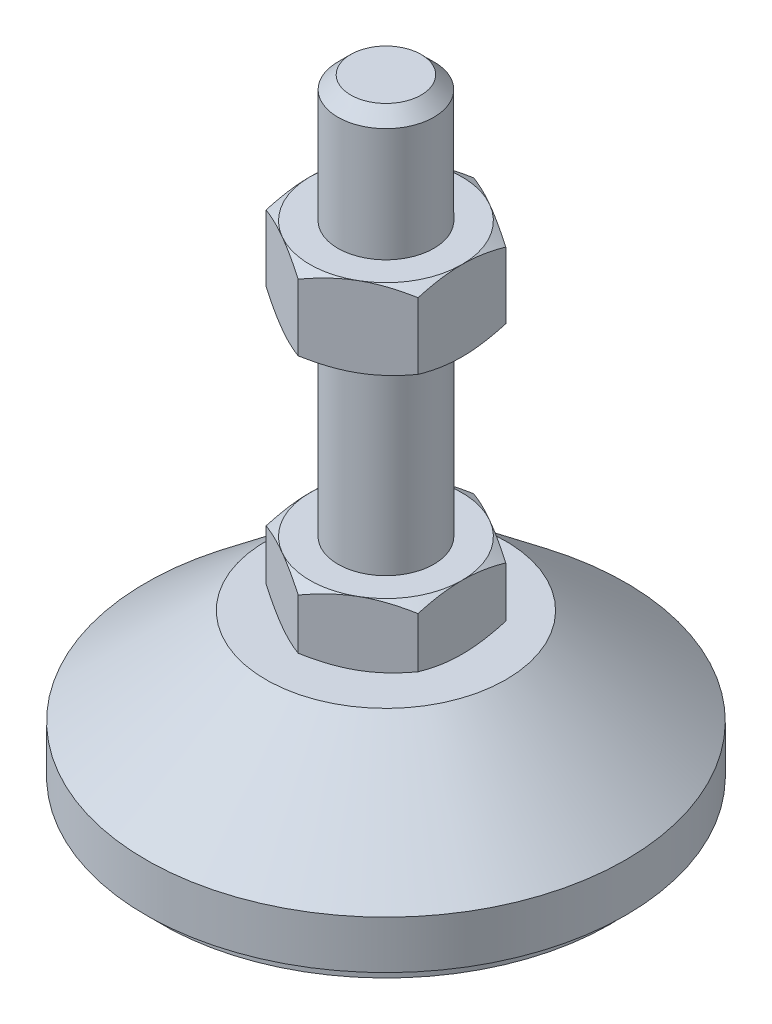
from build123d import *

# Parameters (mm, degrees)
EXTRUDE_1_DEPTH = 8
EXTRUDE_2_DEPTH = 10


with BuildPart() as part:
    # Эскиз1 → Повернуть1 (revolve)
    with BuildSketch(Plane.XY, mode=Mode.PRIVATE) as revolve_1_sk:
        Polygon((0, 0), (-28, 0), (-28, 2), (-30, 2), (-30, 8), (-15, 20), (-6, 20), (-6, 28), (-6, 76.4), (-4.4, 78), (0, 78), align=None)
    revolve(revolve_1_sk.sketch.rotate(Axis((0, 0, 0), (0, 1, 0)), 180), axis=Axis((0, 0, 0), (0, 1, 0)))  # turned: the seam where the file's is

    # Эскиз2 → Бобышка-Вытянуть1 (add)
    with BuildSketch(Plane(origin=(0, 20, 0), x_dir=(1, 0, 0), z_dir=(0, 1, 0))):
        Polygon((0, 10.969655115), (-9.5, 5.484827557), (-9.5, -5.484827557), (0, -10.969655115), (9.5, -5.484827557), (9.5, 5.484827557), align=None)
    extrude(amount=EXTRUDE_1_DEPTH)

    # Эскиз3 → Бобышка-Вытянуть2 (add)
    with BuildSketch(Plane(origin=(0, 52.2, 0), x_dir=(1, 0, 0), z_dir=(0, 1, 0))):
        Polygon((9.5, 5.484827557), (0, 10.969655115), (-9.5, 5.484827557), (-9.5, -5.484827557), (0, -10.969655115), (9.5, -5.484827557), align=None)
    extrude(amount=EXTRUDE_2_DEPTH)

    # Эскиз4 → Вырез-Повернуть2 (revolve, cut)
    with BuildSketch(Plane.XY, mode=Mode.PRIVATE) as cut_revolve_2_sk:
        Polygon((-18.160254038, 62.2), (-9.5, 62.2), (-18.160254038, 57.2), align=None)
        Polygon((-18.160254038, 52.2), (-18.160254038, 57.2), (-9.5, 52.2), align=None)
        Polygon((-16.42820323, 28), (-16.42820323, 24), (-9.5, 28), align=None)
        Polygon((-16.42820323, 24), (-16.42820323, 20), (-9.5, 20), align=None)
    revolve(cut_revolve_2_sk.sketch.rotate(Axis((0, 78, 0), (0, 1, 0)), 180), axis=Axis((0, 78, 0), (0, 1, 0)), mode=Mode.SUBTRACT)  # turned: the seam where the file's is


solid = part.part
